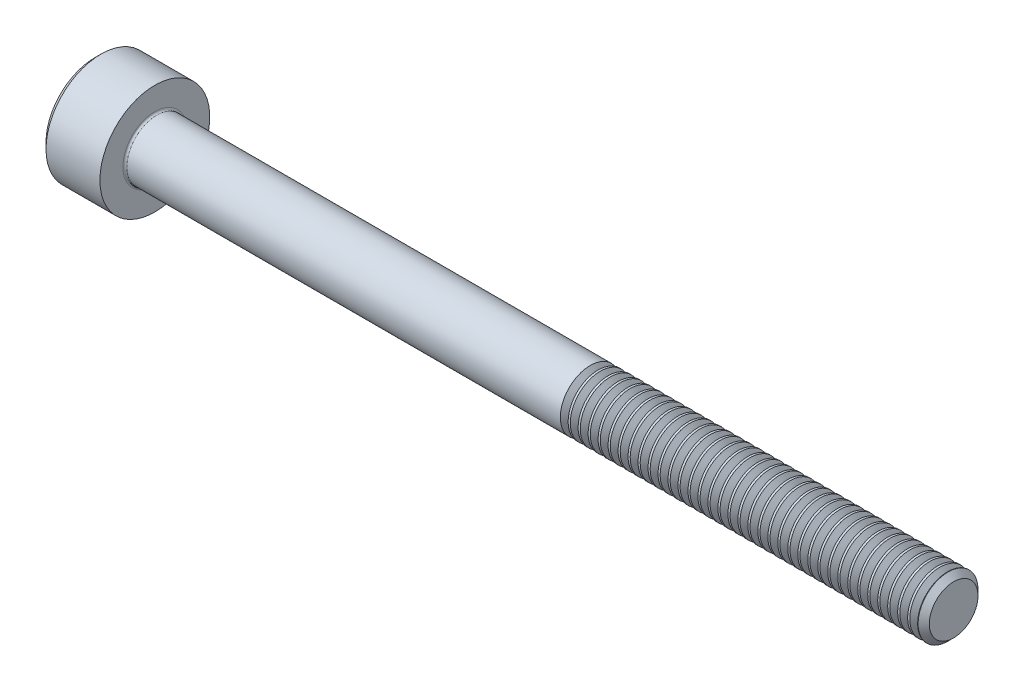
from build123d import *

# Parameters (mm, degrees)
FILLET1_R       = 0.1
HEX_2_DEPTH     = 1.3
THDSCHPAT_COUNT = 37
THDSCHPAT_PITCH = 0.5


with BuildPart() as part:
    # BodySke → Base-Revolve (revolve)
    with BuildSketch(Plane.XY):
        Polygon((0, 0), (0, 2.45), (0.3, 2.75), (3, 2.75), (3, 1.5), (42.7195, 1.5), (43, 1.2195), (43, 0), align=None)
    revolve(axis=Axis((-31.75, 0, 0), (1, 0, 0)))

    # Fillet1
    fillet1_edges = [part.edges().sort_by_distance(p)[0] for p in [
        (3, -1.5, 0),
    ]]
    fillet(fillet1_edges, radius=FILLET1_R)

    # Sketch2 → Hex-PreBroach (revolve, cut)
    with BuildSketch(Plane.XY):
        Polygon((0, 1.28), (1.3, 1.28), (2.039008345, 0), (0, 0), align=None)
    revolve(axis=Axis((0, 0, 0), (1, 0, 0)), mode=Mode.SUBTRACT)

    # Sketch3 → Hex 2 (cut)
    with BuildSketch(Plane(origin=(0, 0, 0), x_dir=(0, 0.5, 0.866025404), z_dir=(-1, 0, 0))):
        Polygon((0.739008345, 1.28), (-0.739008345, 1.28), (-1.478016689, 0), (-0.739008345, -1.28), (0.739008345, -1.28), (1.478016689, 0), align=None)
    extrude(amount=-HEX_2_DEPTH, mode=Mode.SUBTRACT)

    # ThdSchSke → ThreadSchematic (revolve, cut)
    with BuildSketch(Plane.XY):
        Polygon((25, -1.2195), (24.803591786, -1.5), (24.803591786, -1.875), (25.196408214, -1.875), (25.196408214, -1.5), align=None)
    threadschematic = revolve(axis=Axis((-3.175, 0, 0), (1, 0, 0)), mode=Mode.SUBTRACT)

    # ThdSchPat: ThreadSchematic ×37
    with Locations(*[(i * THDSCHPAT_PITCH, 0, 0) for i in range(1, THDSCHPAT_COUNT)]):
        add(threadschematic, mode=Mode.SUBTRACT)


solid = part.part
